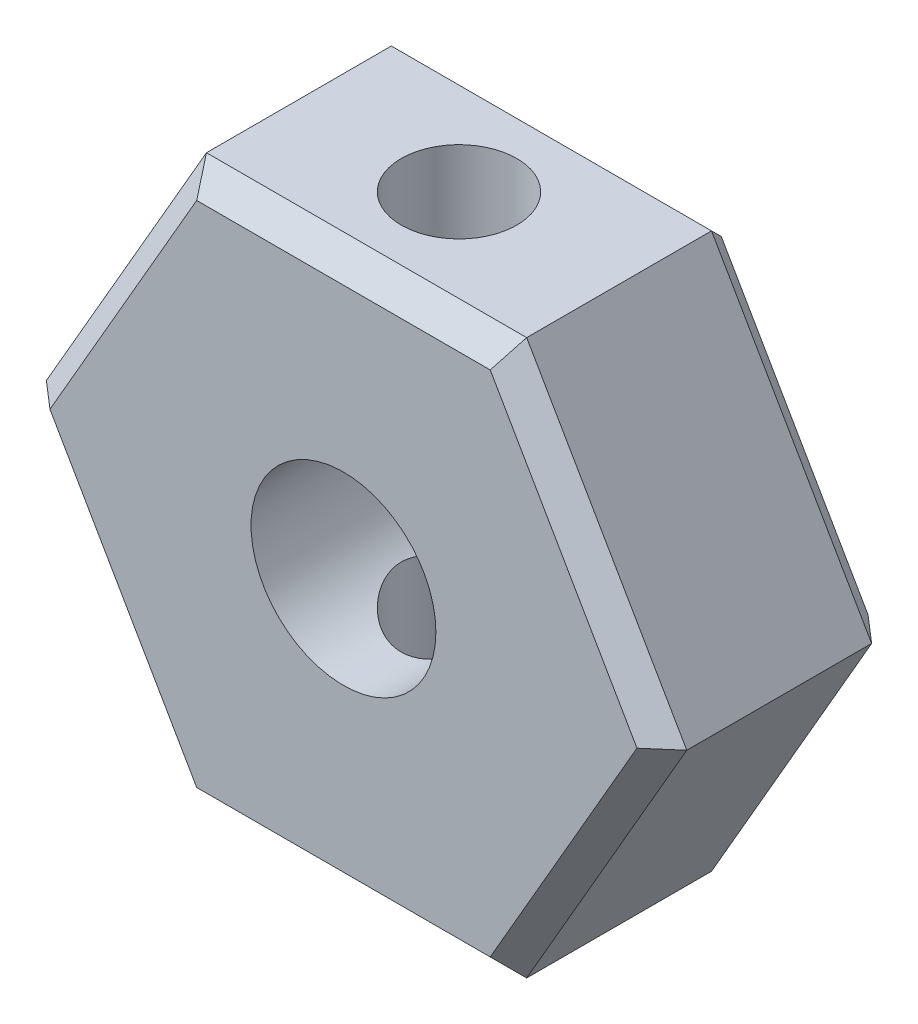
from build123d import *

# Parameters (mm, degrees)
SALIENTE_EXTRUIR1_DEPTH = 5
CROQUIS2_R              = 2
CORTAR_EXTRUIR1_DEPTH   = 5
CHAFL_N1_SIZE           = 0.5
CROQUIS3_R              = 1.25
CORTAR_EXTRUIR2_DEPTH   = 13


with BuildPart() as part:
    # Croquis1 → Saliente-Extruir1 (new body)
    with BuildSketch(Plane.XY):
        Polygon((6.92820323, 0), (3.464101615, 6), (-3.464101615, 6), (-6.92820323, 0), (-3.464101615, -6), (3.464101615, -6), align=None)
    extrude(amount=SALIENTE_EXTRUIR1_DEPTH)

    # Croquis2 → Cortar-Extruir1 (cut)
    with BuildSketch(Plane.XY.offset(5)):
        Circle(CROQUIS2_R)
    extrude(amount=-CORTAR_EXTRUIR1_DEPTH, mode=Mode.SUBTRACT)

    # Chaflán1
    chafl_n1_edges = [part.edges().sort_by_distance(p)[0] for p in [
        (0, 6, 5),
        (-5.196152423, 3, 5),
        (-5.196152423, -3, 5),
        (0, -6, 5),
        (5.196152423, -3, 5),
        (0, -6, 0),
        (-5.196152423, -3, 0),
        (-5.196152423, 3, 0),
        (5.196152423, 3, 5),
        (0, 6, 0),
        (5.196152423, 3, 0),
        (5.196152423, -3, 0),
    ]]
    chamfer(chafl_n1_edges, length=CHAFL_N1_SIZE)

    # Croquis3 → Cortar-Extruir2 (cut, through all)
    with BuildSketch(Plane(origin=(0, 6, 0), x_dir=(1, 0, 0), z_dir=(0, 1, 0))):
        with Locations((0, -2.5)):
            Circle(CROQUIS3_R)
    extrude(amount=-CORTAR_EXTRUIR2_DEPTH, mode=Mode.SUBTRACT)


solid = part.part
